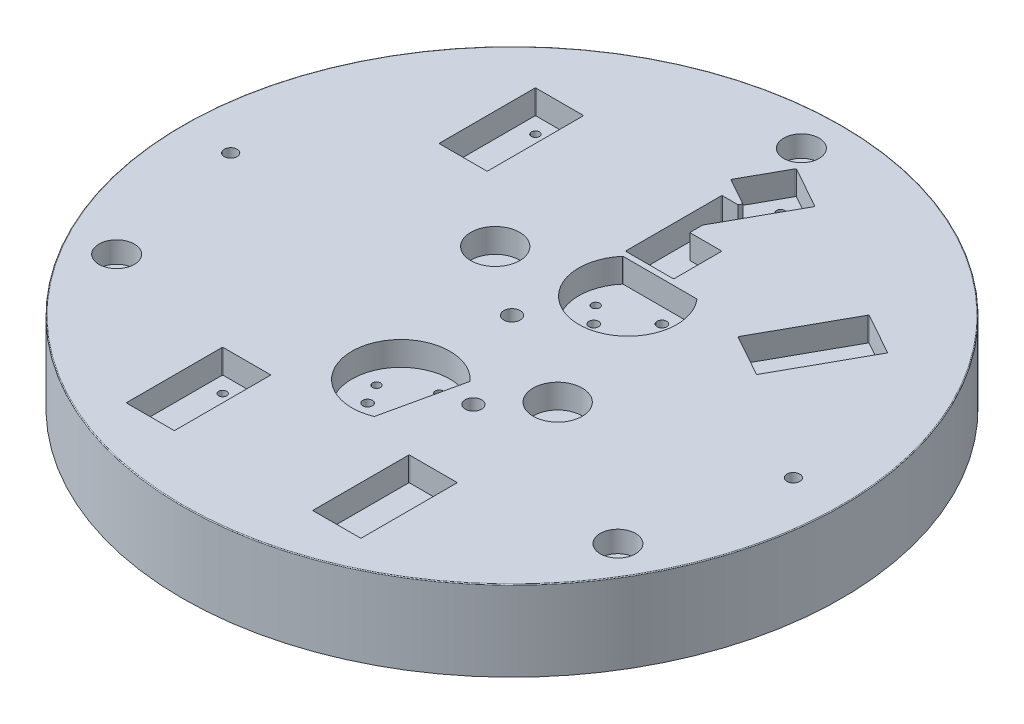
from build123d import *

# Parameters (mm, degrees)
SKETCH1_R              = 205
BOSS_EXTRUDE1_DEPTH    = 50
SKETCH2_R              = 15.25
CUT_EXTRUDE1_DEPTH     = 15
M12_TAPPED_HOLE3_D     = 10.2
M12_TAPPED_HOLE3_DEPTH = 26.185610843
M12_TAPPED_HOLE3_TIP   = 3.064389157
SKETCH3_W              = 30
SKETCH3_H              = 60
CUT_EXTRUDE2_DEPTH     = 15
M6_TAPPED_HOLE3_D      = 5
M6_TAPPED_HOLE3_DEPTH  = 13.497848452
M6_TAPPED_HOLE3_TIP    = 1.502151548
M12_TAPPED_HOLE2_D     = 10.2
M12_TAPPED_HOLE2_DEPTH = 26.185610843
M12_TAPPED_HOLE2_TIP   = 3.064389157
SKETCH35_R             = 4
CUT_EXTRUDE4_DEPTH     = 295.193813667
SKETCH36_R             = 11
CUT_EXTRUDE5_DEPTH     = 13.2
SKETCH37_R             = 7
CUT_EXTRUDE6_DEPTH     = 293.240038325
FILLET1_R              = 0.5
M6_TAPPED_HOLE4_D      = 5
M6_TAPPED_HOLE4_DEPTH  = 13.497848452
M6_TAPPED_HOLE4_TIP    = 1.502151548
M6_TAPPED_HOLE5_D      = 5
M6_TAPPED_HOLE5_DEPTH  = 13.497848452
M6_TAPPED_HOLE5_TIP    = 1.502151548
SKETCH46_R             = 3
CUT_EXTRUDE7_DEPTH     = 15
M12_TAPPED_HOLE1_D     = 10.2
M12_TAPPED_HOLE1_DEPTH = 26.185610843
M12_TAPPED_HOLE1_TIP   = 3.064389157


with BuildPart() as part:
    # Sketch1 → Boss-Extrude1 (new body)
    with BuildSketch(Plane(origin=(0, 0, 0), x_dir=(1, 0, 0), z_dir=(0, 1, 0))):
        Circle(SKETCH1_R)
    extrude(amount=BOSS_EXTRUDE1_DEPTH)

    # Sketch2 → Cut-Extrude1 (cut)
    with BuildSketch(Plane(origin=(0, 50, 0), x_dir=(1, 0, 0), z_dir=(0, 1, 0))):
        with Locations((-42.327685627, 31.896492385)):
            Circle(SKETCH2_R)
        with Locations((60.971197017, -32.546169272)):
            Circle(SKETCH2_R)
        with BuildLine():
            Line((22.508129816, -48.531499254), (11.656226811, -97.298662399))
            ThreePointArc((11.656226811, -97.298662399), (-29.77179649, -62.488909666), (22.508129816, -48.531499254))
        make_face()
        with BuildLine():
            Line((2.66745507, 66.354666069), (48.721770829, 66.354666069))
            ThreePointArc((48.721770829, 66.354666069), (25.69461295, 15.854666069), (2.66745507, 66.354666069))
        make_face()
    extrude(amount=-CUT_EXTRUDE1_DEPTH, mode=Mode.SUBTRACT)

    # M12 Tapped Hole3
    with Locations(Plane(origin=(0, 50, 0), x_dir=(1, 0, 0), z_dir=(0, 1, 0))):
        with Locations((-0.014790744, 0.024833856)):
            Hole(M12_TAPPED_HOLE3_D / 2, depth=M12_TAPPED_HOLE3_DEPTH)
            with Locations((0, 0, -(M12_TAPPED_HOLE3_DEPTH + M12_TAPPED_HOLE3_TIP / 2))):  # 118° drill point
                Cone(0, M12_TAPPED_HOLE3_D / 2, M12_TAPPED_HOLE3_TIP, mode=Mode.SUBTRACT)

    # Sketch3 → Cut-Extrude2 (cut)
    with BuildSketch(Plane(origin=(0, 50, 0), x_dir=(1, 0, 0), z_dir=(0, 1, 0))):
        with Locations((58.112318667, -137.113872591)):
            Rectangle(SKETCH3_W, SKETCH3_H)
        Polygon((137.053029906, 96.676659004), (110.814391162, 111.220861865), (81.72598544, 58.743584377), (107.964624184, 44.199381516), align=None)
        with Locations((-100.327685627, 99.896492385)):
            Rectangle(SKETCH3_W, SKETCH3_H)
        with Locations((-57.887681333, -137.113872591)):
            Rectangle(SKETCH3_W, SKETCH3_H)
        Polygon((35.596960096, 152.9142434), (9.358321352, 167.458446261), (-5.185881509, 141.219807517), (11.746380439, 131.834173793), (10.672314373, 129.896492385), (0.672314373, 129.896492385), (0.672314373, 69.896492385), (30.672314373, 69.896492385), (30.672314373, 99.896492385), (10.672314373, 99.896492385), (10.672314373, 107.948645684), align=None)
    extrude(amount=-CUT_EXTRUDE2_DEPTH, mode=Mode.SUBTRACT)

    # M6 Tapped Hole3
    with Locations(Plane(origin=(0, 35, 0), x_dir=(1, 0, 0), z_dir=(0, 1, 0))):
        with Locations((123.458749371, 92.77851371), (104.06647889, 57.793662051), (-105.327685627, 119.896492385), (-105.327685627, 79.896492385), (-62.887681333, -117.113872591), (-62.887681333, -157.113872591), (63.112318667, -117.113872591), (63.112318667, -157.113872591), (13.256466646, 153.864165726), (20.672314373, 79.896492385)):
            Hole(M6_TAPPED_HOLE3_D / 2, depth=M6_TAPPED_HOLE3_DEPTH)
            with Locations((0, 0, -(M6_TAPPED_HOLE3_DEPTH + M6_TAPPED_HOLE3_TIP / 2))):  # 118° drill point
                Cone(0, M6_TAPPED_HOLE3_D / 2, M6_TAPPED_HOLE3_TIP, mode=Mode.SUBTRACT)

    # M12 Tapped Hole2
    with Locations(Plane(origin=(0, 50, 0), x_dir=(1, 0, 0), z_dir=(0, 1, 0))):
        with Locations((35.989041426, -60.006192032)):
            Hole(M12_TAPPED_HOLE2_D / 2, depth=M12_TAPPED_HOLE2_DEPTH)
            with Locations((0, 0, -(M12_TAPPED_HOLE2_DEPTH + M12_TAPPED_HOLE2_TIP / 2))):  # 118° drill point
                Cone(0, M12_TAPPED_HOLE2_D / 2, M12_TAPPED_HOLE2_TIP, mode=Mode.SUBTRACT)

    # Sketch35 → Cut-Extrude4 (cut, through all)
    with BuildSketch(Plane(origin=(0, 50, 0), x_dir=(1, 0, 0), z_dir=(0, 1, 0))):
        with Locations((-175.014790744, 0.024833856)):
            Circle(SKETCH35_R)
        with Locations((174.985209256, 0.024833856)):
            Circle(SKETCH35_R)
    extrude(amount=-CUT_EXTRUDE4_DEPTH, mode=Mode.SUBTRACT)

    # Sketch36 → Cut-Extrude5 (cut)
    with BuildSketch(Plane(origin=(0, 50, 0), x_dir=(1, 0, 0), z_dir=(0, 1, 0))):
        with Locations((0, 180.024833248)):
            Circle(SKETCH36_R)
        with Locations((155.906078905, -90.012416624)):
            Circle(SKETCH36_R)
        with Locations((-155.906078905, -90.012416624)):
            Circle(SKETCH36_R)
    extrude(amount=-CUT_EXTRUDE5_DEPTH, mode=Mode.SUBTRACT)

    # Sketch37 → Cut-Extrude6 (cut, through all)
    with BuildSketch(Plane(origin=(0, 36.8, 0), x_dir=(1, 0, 0), z_dir=(0, 1, 0))):
        with Locations((0, 180.024833248)):
            Circle(SKETCH37_R)
        with Locations((155.906078905, -90.012416624)):
            Circle(SKETCH37_R)
        with Locations((-155.906078905, -90.012416624)):
            Circle(SKETCH37_R)
    extrude(amount=-CUT_EXTRUDE6_DEPTH, mode=Mode.SUBTRACT)

    # Fillet1
    fillet1_edges = [part.edges().sort_by_distance(p)[0] for p in [
        (-115.327685627, 42.5, -69.896492385),
        (-115.327685627, 42.5, -129.896492385),
        (-85.327685627, 42.5, -129.896492385),
        (-85.327685627, 42.5, -69.896492385),
        (-42.887681333, 42.5, 167.113872591),
        (-42.887681333, 42.5, 107.113872591),
        (-72.887681333, 42.5, 167.113872591),
        (-72.887681333, 42.5, 107.113872591),
        (43.112318667, 42.5, 107.113872591),
        (43.112318667, 42.5, 167.113872591),
        (73.112318667, 42.5, 107.113872591),
        (73.112318667, 42.5, 167.113872591),
        (30.672314373, 42.5, -99.896492385),
        (30.672314373, 42.5, -69.896492385),
        (0.672314373, 42.5, -69.896492385),
        (0.672314373, 42.5, -129.896492385),
        (-5.185881509, 42.5, -141.219807517),
        (9.358321352, 42.5, -167.458446261),
        (35.596960096, 42.5, -152.9142434),
        (137.053029906, 42.5, -96.676659004),
        (110.814391162, 42.5, -111.220861865),
        (107.964624184, 42.5, -44.199381516),
        (81.72598544, 42.5, -58.743584377),
        (-205, 50, 0),
        (11.656226811, 42.5, 97.298662399),
        (22.508129816, 42.5, 48.531499254),
        (48.721770829, 42.5, -66.354666069),
        (2.66745507, 42.5, -66.354666069),
    ]]
    fillet(fillet1_edges, radius=FILLET1_R)

    # M6 Tapped Hole4
    with Locations(Plane(origin=(0, 35, 0), x_dir=(1, 0, 0), z_dir=(0, 1, 0))):
        with Locations((5.69461295, 46.354666069), (25.69461295, 26.354666069), (45.69461295, 46.354666069)):
            Hole(M6_TAPPED_HOLE4_D / 2, depth=M6_TAPPED_HOLE4_DEPTH)
            with Locations((0, 0, -(M6_TAPPED_HOLE4_DEPTH + M6_TAPPED_HOLE4_TIP / 2))):  # 118° drill point
                Cone(0, M6_TAPPED_HOLE4_D / 2, M6_TAPPED_HOLE4_TIP, mode=Mode.SUBTRACT)

    # M6 Tapped Hole5
    with Locations(Plane(origin=(0, 35, 0), x_dir=(1, 0, 0), z_dir=(0, 1, 0))):
        with Locations((-19.522489502, -64.769634607), (4.344237984, -49.591383089), (-4.344237984, -88.636362093)):
            Hole(M6_TAPPED_HOLE5_D / 2, depth=M6_TAPPED_HOLE5_DEPTH)
            with Locations((0, 0, -(M6_TAPPED_HOLE5_DEPTH + M6_TAPPED_HOLE5_TIP / 2))):  # 118° drill point
                Cone(0, M6_TAPPED_HOLE5_D / 2, M6_TAPPED_HOLE5_TIP, mode=Mode.SUBTRACT)

    # Sketch46 → Cut-Extrude7 (cut)
    with BuildSketch(Plane(origin=(0, 35, 0), x_dir=(1, 0, 0), z_dir=(0, 1, 0))):
        with Locations((-12.657243637, -77.163356022)):
            Circle(SKETCH46_R)
        with Locations((12.657243637, -61.06438916)):
            Circle(SKETCH46_R)
        with Locations((15.088011232, 35.748064351)):
            Circle(SKETCH46_R)
        with Locations((36.301214668, 56.961267787)):
            Circle(SKETCH46_R)
    extrude(amount=-CUT_EXTRUDE7_DEPTH, mode=Mode.SUBTRACT)

    # M12 Tapped Hole1
    with Locations(Plane(origin=(0, 35, 0), x_dir=(1, 0, 0), z_dir=(0, 1, 0))):
        with Locations((-42.327685627, 31.896492385), (60.971197017, -32.546169272)):
            Hole(M12_TAPPED_HOLE1_D / 2, depth=M12_TAPPED_HOLE1_DEPTH)
            with Locations((0, 0, -(M12_TAPPED_HOLE1_DEPTH + M12_TAPPED_HOLE1_TIP / 2))):  # 118° drill point
                Cone(0, M12_TAPPED_HOLE1_D / 2, M12_TAPPED_HOLE1_TIP, mode=Mode.SUBTRACT)


solid = part.part
